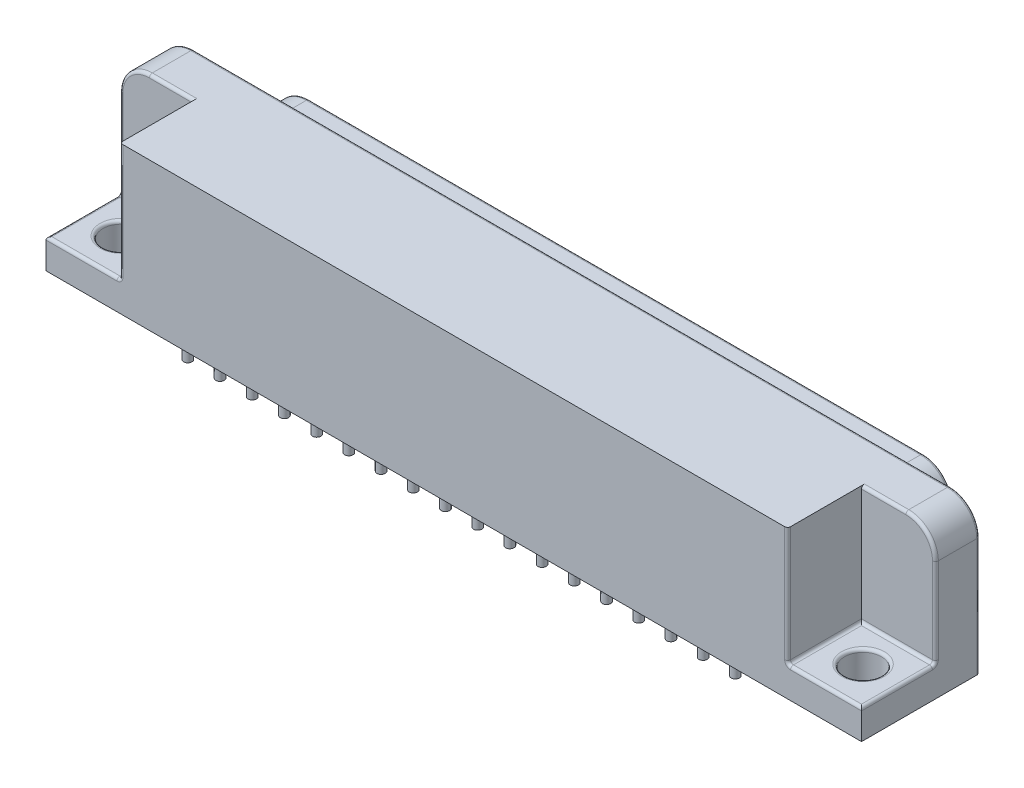
from build123d import *

# Parameters (mm, degrees)
SKETCH1_W           = 70.104
SKETCH1_H           = 10.16
BASE_EXTRUDE_DEPTH  = 12.7
BOSS_EXTRUDE1_DEPTH = 3.81
SKETCH4_R           = 0.635
CUT_EXTRUDE1_DEPTH  = 5.08
SKETCH5_R           = 0.635
CUT_EXTRUDE2_DEPTH  = 5.08
SKETCH6_R           = 0.3556
BOSS_EXTRUDE2_DEPTH = 2.54
LPATTERN1_COUNT     = 19
LPATTERN1_PITCH     = 2.7686
LPATTERN2_COUNT     = 19
LPATTERN2_PITCH     = 2.7686
LPATTERN3_COUNT     = 18
LPATTERN3_PITCH     = 2.7686
SKETCH7_R           = 0.3556
BOSS_EXTRUDE3_DEPTH = 2.54
LPATTERN4_COUNT     = 17
LPATTERN4_PITCH     = 2.7686
SKETCH9_W           = 6.35508
SKETCH9_H           = 10.16
CUT_EXTRUDE3_DEPTH  = 6.35
SKETCH11_R          = 1.5875
CUT_EXTRUDE4_DEPTH  = 6.08
FILLET1_R           = 2.54
FILLET2_R           = 0.254


with BuildPart() as part:
    # Sketch1 → Base-Extrude (new body)
    with BuildSketch(Plane(origin=(0, 0, 0), x_dir=(1, 0, 0), z_dir=(0, 1, 0))):
        with Locations((24.892, 3.048)):
            Rectangle(SKETCH1_W, SKETCH1_H)
    extrude(amount=BASE_EXTRUDE_DEPTH)

    # Sketch2 → Boss-Extrude1 (add)
    with BuildSketch(Plane(origin=(0, 0, -8.128), x_dir=(-1, 0, 0), z_dir=(0, 0, -1))):
        with BuildLine():
            Line((-50.744578513, 2.286), (0.960578513, 2.286))
            ThreePointArc((0.960578513, 2.286), (2.577072218, 2.8667787), (3.454333551, 4.34352118))
            Line((3.454333551, 4.34352118), (3.994902213, 7.13752118))
            ThreePointArc((3.994902213, 7.13752118), (3.460368475, 9.236493705), (1.501147175, 10.16))
            Line((1.501147175, 10.16), (-51.285147175, 10.16))
            ThreePointArc((-51.285147175, 10.16), (-53.244368475, 9.236493705), (-53.778902213, 7.13752118))
            Line((-53.778902213, 7.13752118), (-53.238333551, 4.34352118))
            ThreePointArc((-53.238333551, 4.34352118), (-52.361072218, 2.8667787), (-50.744578513, 2.286))
        make_face()
    extrude(amount=BOSS_EXTRUDE1_DEPTH)

    # Sketch4 → Cut-Extrude1 (cut)
    with BuildSketch(Plane(origin=(0, 0, -11.938), x_dir=(-1, 0, 0), z_dir=(0, 0, -1))):
        with Locations((0, 7.62)):
            Circle(SKETCH4_R)
    cut_extrude1 = extrude(amount=-CUT_EXTRUDE1_DEPTH, mode=Mode.SUBTRACT)

    # Sketch5 → Cut-Extrude2 (cut)
    with BuildSketch(Plane(origin=(0, 0, -11.938), x_dir=(-1, 0, 0), z_dir=(0, 0, -1))):
        with Locations((-1.397, 5.08)):
            Circle(SKETCH5_R)
    cut_extrude2 = extrude(amount=-CUT_EXTRUDE2_DEPTH, mode=Mode.SUBTRACT)

    # Sketch6 → Boss-Extrude2 (add)
    with BuildSketch(Plane.XZ):
        Circle(SKETCH6_R)
    boss_extrude2 = extrude(amount=BOSS_EXTRUDE2_DEPTH)

    # LPattern1: Boss-Extrude2 ×19, 1 skipped
    with Locations(*[(i * LPATTERN1_PITCH, 0, 0) for i in range(1, LPATTERN1_COUNT) if i not in (18,)]):
        add(boss_extrude2)

    # LPattern2: Cut-Extrude1 ×19
    with Locations(*[(i * LPATTERN2_PITCH, 0, 0) for i in range(1, LPATTERN2_COUNT)]):
        add(cut_extrude1, mode=Mode.SUBTRACT)

    # LPattern3: Cut-Extrude2 ×18
    with Locations(*[(i * LPATTERN3_PITCH, 0, 0) for i in range(1, LPATTERN3_COUNT)]):
        add(cut_extrude2, mode=Mode.SUBTRACT)

    # Sketch7 → Boss-Extrude3 (add)
    with BuildSketch(Plane.XZ):
        with Locations((1.397, -2.54)):
            Circle(SKETCH7_R)
    boss_extrude3 = extrude(amount=BOSS_EXTRUDE3_DEPTH)

    # LPattern4: Boss-Extrude3 ×17
    with Locations(*[(i * LPATTERN4_PITCH, 0, 0) for i in range(1, LPATTERN4_COUNT)]):
        add(boss_extrude3)

    # Sketch9 → Cut-Extrude3 (cut)
    with BuildSketch(Plane.XY.offset(2.032)):
        with Locations((-6.98246, 7.62)):
            Rectangle(SKETCH9_W, SKETCH9_H)
    cut_extrude3 = extrude(amount=-CUT_EXTRUDE3_DEPTH, mode=Mode.SUBTRACT)

    # Sketch11 → Cut-Extrude4 (cut, through all)
    with BuildSketch(Plane(origin=(0, 2.54, 0), x_dir=(-1, 0, 0), z_dir=(0, 1, 0))):
        with Locations((6.985, -1.27)):
            Circle(SKETCH11_R)
    cut_extrude4 = extrude(amount=-CUT_EXTRUDE4_DEPTH, mode=Mode.SUBTRACT)

    # Mirror1: Cut-Extrude3, Cut-Extrude4 across plane
    add(cut_extrude3.mirror(Plane(origin=(24.892, 0, 0), x_dir=(0, 0, 1), z_dir=(1, 0, 0))), mode=Mode.SUBTRACT)
    add(cut_extrude4.mirror(Plane(origin=(24.892, 0, 0), x_dir=(0, 0, 1), z_dir=(1, 0, 0))), mode=Mode.SUBTRACT)

    # Fillet1
    fillet1_edges = [part.edges().sort_by_distance(p)[0] for p in [
        (-10.16, 12.7, -6.223),
        (59.944, 12.7, -6.223),
    ]]
    fillet(fillet1_edges, radius=FILLET1_R)

    # Fillet2
    fillet2_edges = [part.edges().sort_by_distance(p)[0] for p in [
        (8.9408, 7.62, -11.938),
        (11.7094, 7.62, -11.938),
        (14.478, 7.62, -11.938),
        (17.2466, 7.62, -11.938),
        (20.0152, 7.62, -11.938),
        (22.7838, 7.62, -11.938),
        (25.5524, 7.62, -11.938),
        (28.321, 7.62, -11.938),
        (31.0896, 7.62, -11.938),
        (33.8582, 7.62, -11.938),
        (36.6268, 7.62, -11.938),
        (39.3954, 7.62, -11.938),
        (42.164, 7.62, -11.938),
        (44.9326, 7.62, -11.938),
        (47.7012, 7.62, -11.938),
        (50.4698, 7.62, -11.938),
        (4.8006, 5.08, -11.938),
        (7.5692, 5.08, -11.938),
        (10.3378, 5.08, -11.938),
        (13.1064, 5.08, -11.938),
        (15.875, 5.08, -11.938),
        (18.6436, 5.08, -11.938),
        (21.4122, 5.08, -11.938),
        (24.1808, 5.08, -11.938),
        (26.9494, 5.08, -11.938),
        (29.718, 5.08, -11.938),
        (32.4866, 5.08, -11.938),
        (35.2552, 5.08, -11.938),
        (38.0238, 5.08, -11.938),
        (40.7924, 5.08, -11.938),
        (-2.577072218, 2.8667787, -11.938),
        (43.561, 5.08, -11.938),
        (-3.724617882, 5.74052118, -11.938),
        (46.3296, 5.08, -11.938),
        (-3.460368475, 9.236493705, -11.938),
        (49.0982, 5.08, -11.938),
        (24.892, 10.16, -11.938),
        (53.244368475, 9.236493705, -11.938),
        (53.508617882, 5.74052118, -11.938),
        (52.361072218, 2.8667787, -11.938),
        (24.892, 2.286, -11.938),
        (-10.16, 2.54, -1.143),
        (-5.71246, 12.7, -4.318),
        (-6.98246, 2.54, -4.318),
        (-3.80492, 2.54, -1.143),
        (-6.98246, 2.54, 2.032),
        (-3.80492, 7.62, 2.032),
        (-5.3975, 2.54, -1.27),
        (56.76646, 2.54, 2.032),
        (59.944, 2.54, -1.143),
        (53.58892, 7.62, 2.032),
        (53.58892, 2.54, -1.143),
        (56.76646, 2.54, -4.318),
        (55.49646, 12.7, -4.318),
        (55.1815, 2.54, -1.27),
        (24.892, 12.7, -8.128),
        (-10.16, 6.35, -4.318),
        (-9.416051224, 11.956051224, -4.318),
        (-10.16, 5.08, -8.128),
        (59.944, 5.08, -8.128),
        (59.200051224, 11.956051224, -8.128),
        (-9.416051224, 11.956051224, -8.128),
        (59.944, 6.35, -4.318),
        (59.200051224, 11.956051224, -4.318),
        (0.635, 7.62, -11.938),
        (2.032, 5.08, -11.938),
        (3.4036, 7.62, -11.938),
        (6.1722, 7.62, -11.938),
    ]]
    fillet(fillet2_edges, radius=FILLET2_R)


solid = part.part
